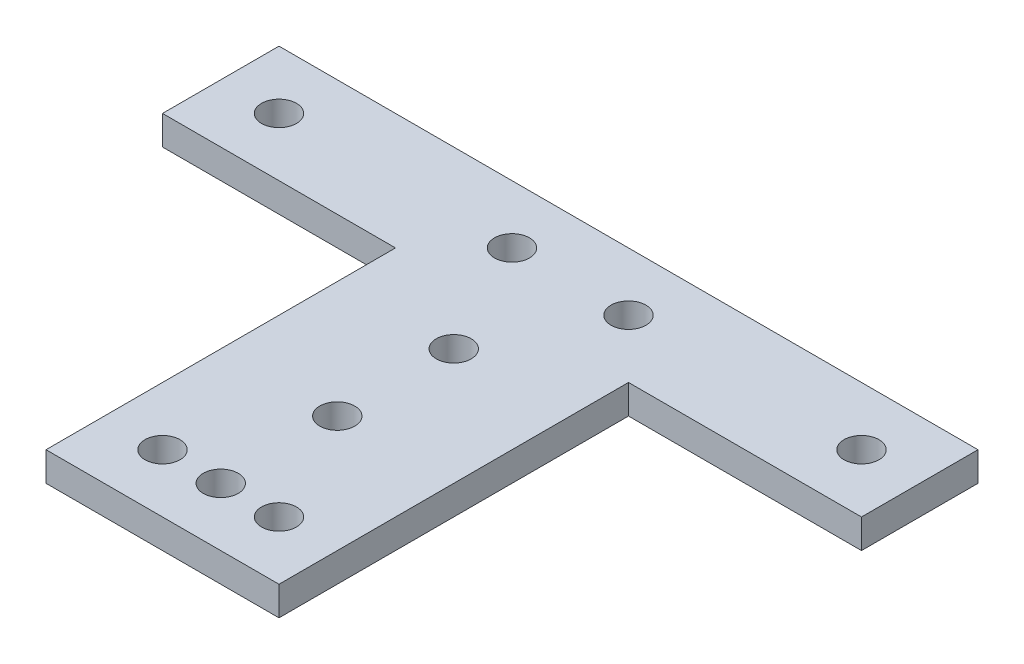
from build123d import *

# Parameters (mm, degrees)
ESQUISSE1_R        = 1.5
BOSS_EXTRU_1_DEPTH = 2.5


with BuildPart() as part:
    # Esquisse1 → Boss.-Extru.1 (new body)
    with BuildSketch(Plane(origin=(0, 0, 0), x_dir=(1, 0, 0), z_dir=(0, 1, 0))):
        Polygon((-30, -5), (-10, -5), (-10, -35), (10, -35), (10, -5), (30, -5), (30, 5), (-30, 5), align=None)
        with Locations((-25, 0)):
            Circle(ESQUISSE1_R, mode=Mode.SUBTRACT)
        with Locations((25, 0)):
            Circle(ESQUISSE1_R, mode=Mode.SUBTRACT)
        with Locations((-5, 0)):
            Circle(ESQUISSE1_R, mode=Mode.SUBTRACT)
        with Locations((5, 0)):
            Circle(ESQUISSE1_R, mode=Mode.SUBTRACT)
        with Locations((-5, -30)):
            Circle(ESQUISSE1_R, mode=Mode.SUBTRACT)
        with Locations((5, -30)):
            Circle(ESQUISSE1_R, mode=Mode.SUBTRACT)
        with Locations((0, -30)):
            Circle(ESQUISSE1_R, mode=Mode.SUBTRACT)
        with Locations((0, -20)):
            Circle(ESQUISSE1_R, mode=Mode.SUBTRACT)
        with Locations((0, -10)):
            Circle(ESQUISSE1_R, mode=Mode.SUBTRACT)
    extrude(amount=BOSS_EXTRU_1_DEPTH)


solid = part.part
